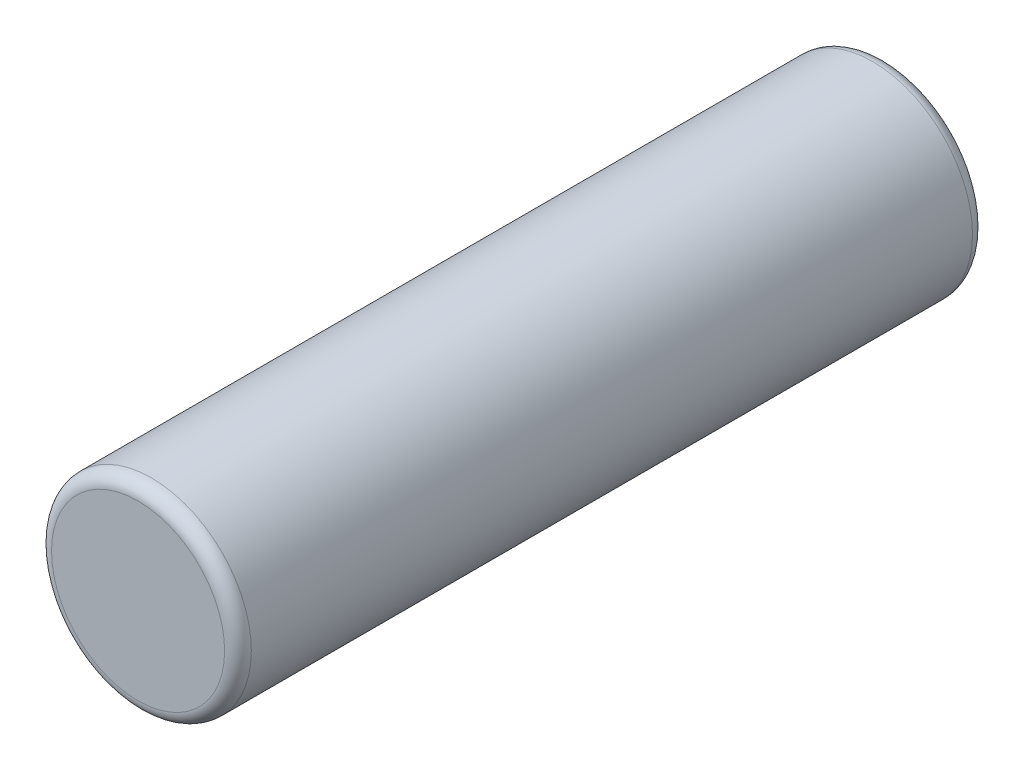
from build123d import *

# Parameters (mm, degrees)
SKETCH1_R           = 47.498
BOSS_EXTRUDE1_DEPTH = 355.6
FILLET1_R           = 6.35


with BuildPart() as part:
    # Sketch1 → Boss-Extrude1 (new body)
    with BuildSketch(Plane.XY):
        Circle(SKETCH1_R)
    extrude(amount=-BOSS_EXTRUDE1_DEPTH)

    # Fillet1
    fillet1_edges = [part.edges().sort_by_distance(p)[0] for p in [
        (-47.498, 0, 0),
        (-47.498, 0, -355.6),
    ]]
    fillet(fillet1_edges, radius=FILLET1_R)


solid = part.part
